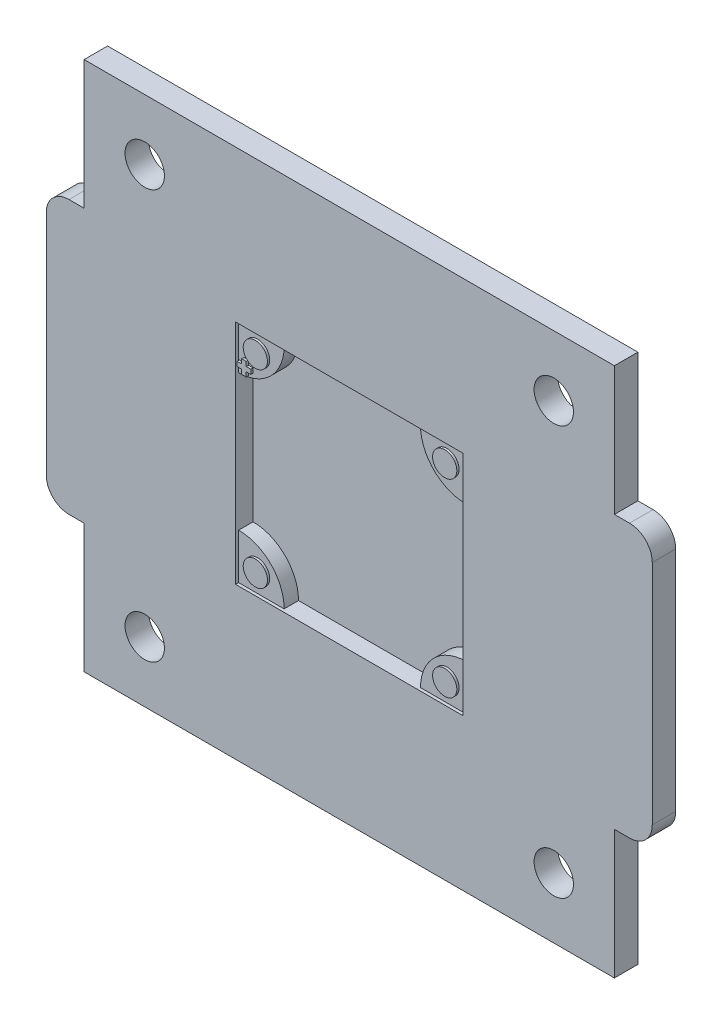
from build123d import *

# Parameters (mm, degrees)
SKETCH_1_W          = 70
SKETCH_1_H          = 70
EXTRUDE_1_DEPTH     = 3.1
SKETCH_2_W          = 30
SKETCH_2_H          = 30
CUT_EXTRUDE_1_DEPTH = 2.3
SKETCH_3_R          = 2.6
CUT_EXTRUDE_2_DEPTH = 4.1
EXTRUDE_2_DEPTH     = 2.7
SKETCH_6_R          = 1.6
EXTRUDE_3_DEPTH     = 0.3


with BuildPart() as part:
    # 草图1 → 凸台-拉伸1 (new body)
    with BuildSketch(Plane.XY):
        with BuildLine():
            Line((-2, 17), (0, 17))
            Line((0, 17), (0, 53))
            Line((0, 53), (-2, 53))
            ThreePointArc((-2, 53), (-4.121320344, 52.121320344), (-5, 50))
            Line((-5, 50), (-5, 20))
            ThreePointArc((-5, 20), (-4.121320344, 17.878679656), (-2, 17))
        make_face()
        with Locations((35, 35)):
            Rectangle(SKETCH_1_W, SKETCH_1_H)
        with BuildLine():
            Line((70, 53), (70, 17))
            Line((70, 17), (72, 17))
            ThreePointArc((72, 17), (74.121320344, 17.878679656), (75, 20))
            Line((75, 20), (75, 50))
            ThreePointArc((75, 50), (74.121320344, 52.121320344), (72, 53))
            Line((72, 53), (70, 53))
        make_face()
    extrude(amount=EXTRUDE_1_DEPTH)

    # 草图2 → 切除-拉伸1 (cut)
    with BuildSketch(Plane.XY.offset(3.1)):
        with Locations((35, 35)):
            Rectangle(SKETCH_2_W, SKETCH_2_H)
    extrude(amount=-CUT_EXTRUDE_1_DEPTH, mode=Mode.SUBTRACT)

    # 草图3 → 切除-拉伸2 (cut, through all)
    with BuildSketch(Plane.XY.offset(3.1)):
        with Locations((8, 62)):
            Circle(SKETCH_3_R)
        with Locations((62, 62)):
            Circle(SKETCH_3_R)
        with Locations((8, 8)):
            Circle(SKETCH_3_R)
        with Locations((62, 8)):
            Circle(SKETCH_3_R)
    extrude(amount=-CUT_EXTRUDE_2_DEPTH, mode=Mode.SUBTRACT)

    # 草图4 → 凸台-拉伸2 (add)
    with BuildSketch(Plane.XY):
        with BuildLine():
            Line((20, 44), (20, 50))
            Line((20, 50), (26, 50))
            ThreePointArc((26, 50), (24.242640687, 45.757359313), (20, 44))
        make_face()
        with BuildLine():
            Line((50, 44), (50, 50))
            Line((50, 50), (44, 50))
            ThreePointArc((44, 50), (45.757359313, 45.757359313), (50, 44))
        make_face()
        with BuildLine():
            Line((50, 20), (44, 20))
            ThreePointArc((44, 20), (45.757359313, 24.242640687), (50, 26))
            Line((50, 26), (50, 20))
        make_face()
        with BuildLine():
            Line((20, 26), (20, 20))
            Line((20, 20), (26, 20))
            ThreePointArc((26, 20), (24.242640687, 24.242640687), (20, 26))
        make_face()
    extrude(amount=EXTRUDE_2_DEPTH)

    # 草图6 → 凸台-拉伸3 (add)
    with BuildSketch(Plane.XY.offset(2.7)):
        with Locations((22.5, 47.5)):
            Circle(SKETCH_6_R)
        with Locations((47.5, 47.5)):
            Circle(SKETCH_6_R)
        with Locations((47.5, 22.5)):
            Circle(SKETCH_6_R)
        with Locations((22.5, 22.5)):
            Circle(SKETCH_6_R)
        Polygon((20.1, 45.5), (20.7, 45.5), (20.7, 46.1), (21.3, 46.1), (21.3, 45.5), (21.9, 45.5), (21.9, 44.9), (21.3, 44.9), (21.3, 44.3), (20.7, 44.3), (20.7, 44.9), (20.1, 44.9), align=None)
    extrude(amount=EXTRUDE_3_DEPTH)


solid = part.part
